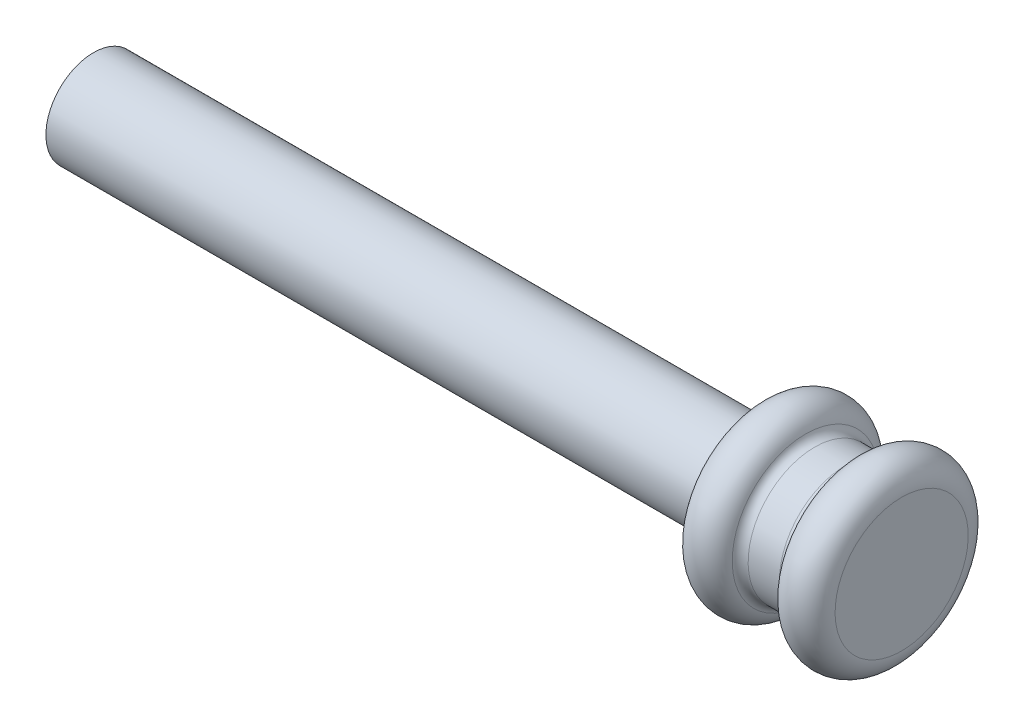
from build123d import *

# Parameters (mm, degrees)
SKETCH2_R           = 5
BOSS_EXTRUDE1_DEPTH = 85


with BuildPart() as part:
    # Sketch1 → Revolve2 (revolve)
    with BuildSketch(Plane.XY):
        with BuildLine():
            ThreePointArc((6.40625, 0), (4.267173955, 2.473809592), (1.510462881, 0.714285714))
            ThreePointArc((1.510462881, 0.714285714), (1.149762338, 0.198216274), (0.552148034, 0))
            Line((0.552148034, 0), (-2.739648034, 0))
            ThreePointArc((-2.739648034, 0), (-3.337262338, 0.198216274), (-3.697962881, 0.714285714))
            ThreePointArc((-3.697962881, 0.714285714), (-6.454673955, 2.473809592), (-8.59375, 0))
            Line((-8.59375, 0), (-8.59375, -2))
            Line((-8.59375, -2), (6.40625, -2))
            Line((6.40625, -2), (6.40625, 0))
        make_face()
    revolve(axis=Axis((11.035645008, -7, 0), (-1, 0, 0)))

    # Sketch2 → Boss-Extrude1 (add)
    with BuildSketch(Plane(origin=(6.40625, 0, 0), x_dir=(0, 0, -1), z_dir=(1, 0, 0))):
        with Locations((0, -7)):
            Circle(SKETCH2_R)
    extrude(amount=-BOSS_EXTRUDE1_DEPTH)


solid = part.part
